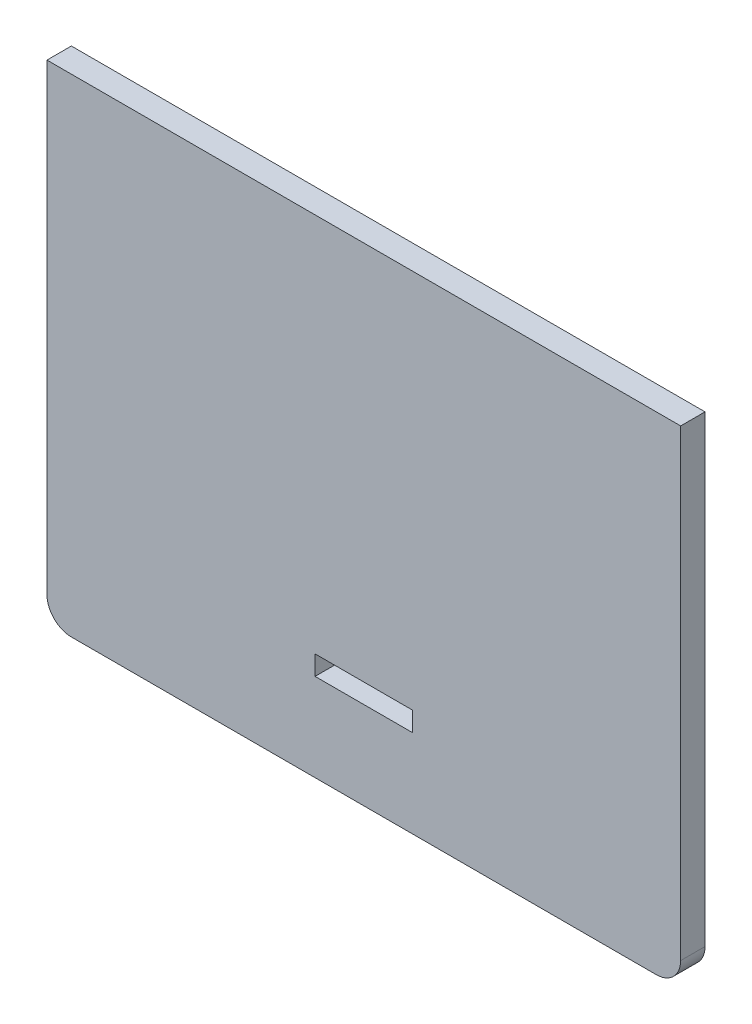
from build123d import *

# Parameters (mm, degrees)
SKETCH2_W           = 130
SKETCH2_H           = 100
BOSS_EXTRUDE1_DEPTH = 2.5
FILLET1_R           = 5
SKETCH3_W           = 20
SKETCH3_H           = 4
CUT_EXTRUDE1_DEPTH  = 5


with BuildPart() as part:
    # Sketch2 → Boss-Extrude1 (new body, symmetric)
    with BuildSketch(Plane.XY):
        Rectangle(SKETCH2_W, SKETCH2_H)
    extrude(amount=BOSS_EXTRUDE1_DEPTH, both=True)

    # Fillet1
    fillet1_edges = [part.edges().sort_by_distance(p)[0] for p in [
        (-65, -50, 0),
        (65, -50, 0),
    ]]
    fillet(fillet1_edges, radius=FILLET1_R)

    # Sketch3 → Cut-Extrude1 (cut)
    with BuildSketch(Plane.XY.offset(2.5)):
        with Locations((0, -30)):
            Rectangle(SKETCH3_W, SKETCH3_H)
    extrude(amount=-CUT_EXTRUDE1_DEPTH, mode=Mode.SUBTRACT)


solid = part.part
